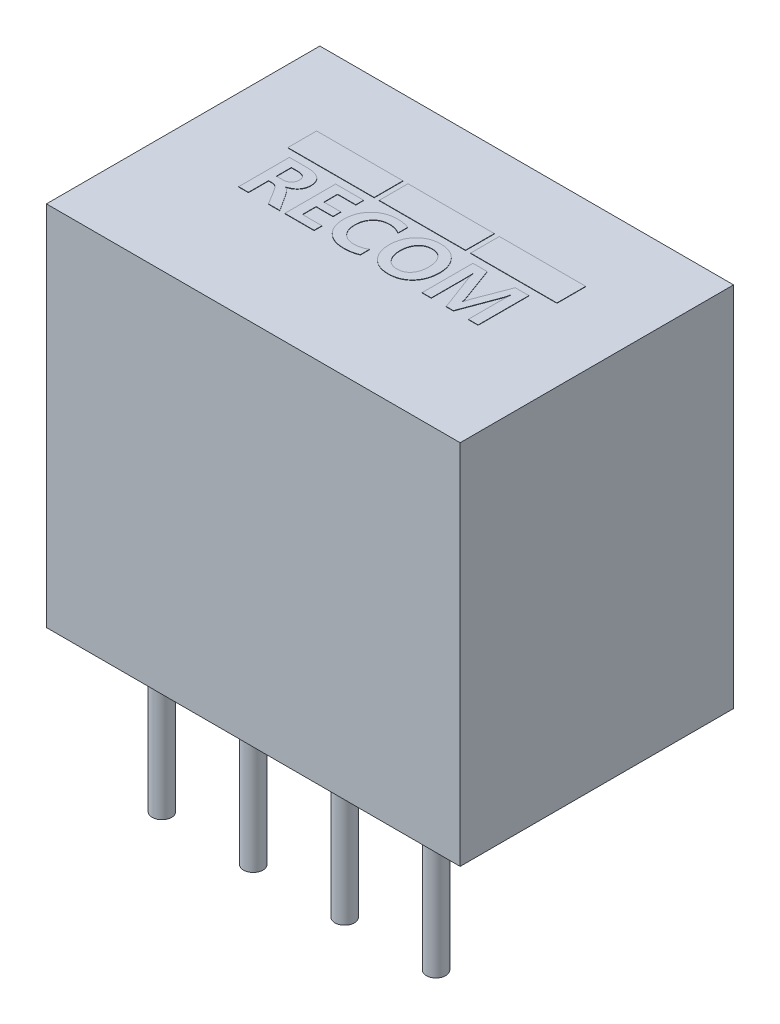
from build123d import *

# Parameters (mm, degrees)
SKETCH1_W           = 11.5
SKETCH1_H           = 7.6
BOSS_EXTRUDE1_DEPTH = 10.2
SKETCH1_3_R         = 0.27
BOSS_EXTRUDE2_DEPTH = 4.1
SKETCH2_W           = 2.4
SKETCH2_H           = 0.8
BOSS_EXTRUDE3_DEPTH = 0.01


with BuildPart() as part:
    # Sketch1 → Boss-Extrude1 (new body)
    with BuildSketch(Plane(origin=(0, 0, 0), x_dir=(1, 0, 0), z_dir=(0, 1, 0))):
        Rectangle(SKETCH1_W, SKETCH1_H)
    extrude(amount=BOSS_EXTRUDE1_DEPTH)

    # Sketch1_3 → Boss-Extrude2 (add)
    with BuildSketch(Plane(origin=(0, 0, 0), x_dir=(1, 0, 0), z_dir=(0, 1, 0))):
        with Locations((-1.27, -2.53)):
            Circle(SKETCH1_3_R)
        with Locations((-3.81, -2.53)):
            Circle(SKETCH1_3_R)
        with Locations((1.27, -2.53)):
            Circle(SKETCH1_3_R)
        with Locations((3.81, -2.53)):
            Circle(SKETCH1_3_R)
    extrude(amount=-BOSS_EXTRUDE2_DEPTH)

    # Sketch2 → Boss-Extrude3 (add)
    # profile 1 of 8: a face of its own
    with BuildSketch(Plane(origin=(0, 10.2, 0), x_dir=(1, 0, 0), z_dir=(0, 1, 0))):
        with Locations((-2.54, 1.3)):
            Rectangle(SKETCH2_W, SKETCH2_H)
    # profile 2 of 8: a face of its own
    with BuildSketch(Plane(origin=(0, 10.2, 0), x_dir=(1, 0, 0), z_dir=(0, 1, 0))):
        with Locations((0, 1.3)):
            Rectangle(SKETCH2_W, SKETCH2_H)
    # profile 3 of 8: a face of its own
    with BuildSketch(Plane(origin=(0, 10.2, 0), x_dir=(1, 0, 0), z_dir=(0, 1, 0))):
        with Locations((2.54, 1.3)):
            Rectangle(SKETCH2_W, SKETCH2_H)
    # profile 4 of 8: a face of its own
    with BuildSketch(Plane(origin=(0, 10.2, 0), x_dir=(1, 0, 0), z_dir=(0, 1, 0))):
        with BuildLine():
            Line((-2.338196915, -0.724408757), (-2.65301943, -0.724408757))
            Line((-2.65301943, -0.724408757), (-2.883342903, -0.349108668))
            add(Edge.make_bspline(
                [(-2.883342903, -0.349108668), (-2.889065834, -0.340050627), (-2.900091741, -0.322599234), (-2.916365352, -0.297671625), (-2.932259878, -0.275279056), (-2.947432976, -0.255296175), (-2.961810385, -0.237635019), (-2.975635139, -0.222577053), (-2.988971428, -0.210025145), (-3.005690975, -0.196649572), (-3.026658096, -0.183273787), (-3.053158879, -0.172174303), (-3.080505396, -0.164993724), (-3.099209874, -0.164144745), (-3.108579478, -0.163719467)],
                knots=[0, 0, 0, 0, 1.260290004, 2.42809852, 3.501063779, 4.489453867, 5.378993215, 6.178776943, 6.892148797, 7.530688844, 8.695813405, 9.803017637, 10.899469084, 12, 12, 12, 12], degree=3))
            Line((-3.108579478, -0.163719467), (-3.210882665, -0.163719467))
            Line((-3.210882665, -0.163719467), (-3.210882665, -0.724408757))
            Line((-3.210882665, -0.724408757), (-3.482183935, -0.724408757))
            Line((-3.482183935, -0.724408757), (-3.482183935, 0.686357844))
            Line((-3.482183935, 0.686357844), (-2.998645943, 0.686357844))
            add(Edge.make_bspline(
                [(-2.998645943, 0.686357844), (-2.978759066, 0.68613297), (-2.940154994, 0.685696448), (-2.884210544, 0.681017461), (-2.832042266, 0.67394387), (-2.783805556, 0.663390469), (-2.739253312, 0.650351489), (-2.698611576, 0.633840907), (-2.661689509, 0.614700878), (-2.628533661, 0.592610205), (-2.599432456, 0.567194833), (-2.57413811, 0.538831914), (-2.552755212, 0.507484911), (-2.535429386, 0.473147775), (-2.521784922, 0.435895451), (-2.51231233, 0.395572491), (-2.50662651, 0.352386367), (-2.505882034, 0.32266239), (-2.505499364, 0.307383883)],
                knots=[0, 0, 0, 0, 1.344225702, 2.609388402, 3.792916859, 4.900986039, 5.94475571, 6.927577767, 7.861970238, 8.752257416, 9.614421308, 10.467028435, 11.314960308, 12.172311822, 13.060888771, 13.990842711, 14.967267346, 16, 16, 16, 16], degree=3))
            add(Edge.make_bspline(
                [(-2.505499364, 0.307383883), (-2.505811899, 0.295977182), (-2.506425671, 0.273576056), (-2.510059685, 0.240455497), (-2.516630851, 0.20852752), (-2.525587337, 0.177659765), (-2.537395774, 0.14804604), (-2.551327957, 0.119384837), (-2.568675725, 0.092288835), (-2.587607134, 0.065874033), (-2.609560455, 0.041454545), (-2.633275923, 0.018262282), (-2.659669621, -0.002502448), (-2.688116325, -0.02157601), (-2.718701939, -0.038719896), (-2.751359485, -0.05444119), (-2.786354582, -0.067957827), (-2.810754066, -0.075239201), (-2.823147934, -0.07893782)],
                knots=[0, 0, 0, 0, 1.012628693, 1.98865752, 2.95290287, 3.90279304, 4.837546914, 5.779899327, 6.726508346, 7.689846888, 8.661316233, 9.637058477, 10.630834735, 11.637334308, 12.674488052, 13.740399365, 14.85222202, 16, 16, 16, 16], degree=3))
            Line((-2.823147934, -0.07893782), (-2.823147934, -0.082894297))
            add(Edge.make_bspline(
                [(-2.823147934, -0.082894297), (-2.814922312, -0.086129796), (-2.797504469, -0.092981001), (-2.772590452, -0.10914122), (-2.746598042, -0.129277061), (-2.720574331, -0.154728798), (-2.693508973, -0.184513059), (-2.666417911, -0.219505154), (-2.637882133, -0.258772484), (-2.619793685, -0.287297436), (-2.610346001, -0.302196156)],
                knots=[0, 0, 0, 0, 0.68144638, 1.442970127, 2.283088423, 3.220039647, 4.250693704, 5.390878668, 6.637243303, 8, 8, 8, 8], degree=3))
            Line((-2.610346001, -0.302196156), (-2.338196915, -0.724408757))
        make_face()
        with BuildLine():
            Line((-3.210882665, 0.469316829), (-3.210882665, 0.053321549))
            Line((-3.210882665, 0.053321549), (-3.044428032, 0.053321549))
            add(Edge.make_bspline(
                [(-3.044428032, 0.053321549), (-3.035184275, 0.053419179), (-3.017111369, 0.05361006), (-2.99079002, 0.057003248), (-2.965738314, 0.061535933), (-2.942334152, 0.068718406), (-2.920289009, 0.077559856), (-2.89952861, 0.088125392), (-2.880608, 0.101464691), (-2.86282623, 0.115902806), (-2.847006029, 0.132099694), (-2.833062523, 0.149401037), (-2.821173153, 0.167749575), (-2.811466768, 0.187074111), (-2.8041627, 0.207316628), (-2.79866061, 0.228385737), (-2.795585693, 0.250583939), (-2.79512334, 0.265737704), (-2.794887385, 0.273471225)],
                knots=[0, 0, 0, 0, 1.187793523, 2.322311229, 3.408112548, 4.458252248, 5.463842587, 6.460858338, 7.445431271, 8.435059429, 9.403096374, 10.350986816, 11.288524295, 12.20955774, 13.125557959, 14.05112169, 15.005416088, 16, 16, 16, 16], degree=3))
            add(Edge.make_bspline(
                [(-2.794887385, 0.273471225), (-2.79496863, 0.281400893), (-2.795126014, 0.296761949), (-2.798677501, 0.318989863), (-2.802715645, 0.339894264), (-2.809734812, 0.359098312), (-2.818544175, 0.376676888), (-2.829026622, 0.393003302), (-2.841524077, 0.407659029), (-2.855779488, 0.421007835), (-2.872460977, 0.432037572), (-2.890436375, 0.442548749), (-2.910880369, 0.450445848), (-2.932873623, 0.457690274), (-2.9569343, 0.462935406), (-2.98282602, 0.466520233), (-3.010569008, 0.468812421), (-3.029727902, 0.469145031), (-3.039623739, 0.469316829)],
                knots=[0, 0, 0, 0, 1.060683122, 2.054715356, 3.010109701, 3.908198541, 4.782933072, 5.640477322, 6.500061802, 7.357420336, 8.246509795, 9.17313587, 10.140950282, 11.174564491, 12.27366142, 13.433661261, 14.67445015, 16, 16, 16, 16], degree=3))
            Line((-3.039623739, 0.469316829), (-3.210882665, 0.469316829))
        make_face(mode=Mode.SUBTRACT)
    # profile 5 of 8: a face of its own
    with BuildSketch(Plane(origin=(0, 10.2, 0), x_dir=(1, 0, 0), z_dir=(0, 1, 0))):
        Polygon((-1.384120784, -0.724408757), (-2.198024592, -0.724408757), (-2.198024592, 0.686357844), (-1.420294286, 0.686357844), (-1.420294286, 0.469316829), (-1.926723323, 0.469316829), (-1.926723323, 0.089495051), (-1.456467789, 0.089495051), (-1.456467789, -0.127545964), (-1.926723323, -0.127545964), (-1.926723323, -0.507367742), (-1.384120784, -0.507367742), align=None)
    # profile 6 of 8: a face of its own
    with BuildSketch(Plane(origin=(0, 10.2, 0), x_dir=(1, 0, 0), z_dir=(0, 1, 0))):
        with BuildLine():
            add(Edge.make_bspline(
                [(-0.154221695, -0.665626815), (-0.167409603, -0.67187969), (-0.194284474, -0.684622059), (-0.237247822, -0.699864047), (-0.28277611, -0.71327562), (-0.331348516, -0.723862351), (-0.382650913, -0.732368187), (-0.436911282, -0.738133908), (-0.493952086, -0.741967244), (-0.533000606, -0.742316716), (-0.55297804, -0.742495509)],
                knots=[0, 0, 0, 0, 0.854610224, 1.741560423, 2.667229016, 3.634022525, 4.652059021, 5.712565366, 6.829736085, 8, 8, 8, 8], degree=3))
            add(Edge.make_bspline(
                [(-0.55297804, -0.742495509), (-0.578444379, -0.742039563), (-0.628227816, -0.741148249), (-0.70089694, -0.731643104), (-0.769826417, -0.71739551), (-0.834591519, -0.696208217), (-0.89548778, -0.669653563), (-0.952459884, -0.637003705), (-1.005140164, -0.597978701), (-1.053812492, -0.553641326), (-1.097415409, -0.504325985), (-1.135733651, -0.450846253), (-1.167658204, -0.393073821), (-1.194060871, -0.331559731), (-1.214378792, -0.266077451), (-1.229061109, -0.196757057), (-1.237943081, -0.123444467), (-1.238925247, -0.073216601), (-1.239426773, -0.047568611)],
                knots=[0, 0, 0, 0, 1.108083605, 2.166161779, 3.185316522, 4.168407951, 5.127001825, 6.073171303, 7.020584339, 7.975671295, 8.934423073, 9.881258946, 10.834097879, 11.802346283, 12.790761351, 13.813926859, 14.883719571, 16, 16, 16, 16], degree=3))
            add(Edge.make_bspline(
                [(-1.239426773, -0.047568611), (-1.2387439, -0.02060115), (-1.237404736, 0.032284041), (-1.227827469, 0.109736336), (-1.211196819, 0.183342659), (-1.188954365, 0.253450352), (-1.159017795, 0.319394577), (-1.123557197, 0.382017535), (-1.080683459, 0.440339723), (-1.032293897, 0.494819523), (-0.978660929, 0.543926423), (-0.920888807, 0.587062483), (-0.859247915, 0.623334197), (-0.794022474, 0.653153909), (-0.725030168, 0.676154145), (-0.652407343, 0.692395546), (-0.576060449, 0.702539506), (-0.523901784, 0.703801217), (-0.497304759, 0.704444596)],
                knots=[0, 0, 0, 0, 1.091637854, 2.140782853, 3.152958058, 4.143081971, 5.112656685, 6.079497617, 7.051289739, 8.037174344, 9.025070473, 9.989908742, 10.950691321, 11.914888765, 12.888094087, 13.889108241, 14.923602787, 16, 16, 16, 16], degree=3))
            add(Edge.make_bspline(
                [(-0.497304759, 0.704444596), (-0.480531854, 0.704318736), (-0.447714472, 0.704072482), (-0.399550067, 0.701063843), (-0.353413615, 0.696730846), (-0.30939758, 0.690146577), (-0.267453406, 0.682134717), (-0.227802001, 0.671788255), (-0.190018316, 0.660174569), (-0.166029253, 0.650449427), (-0.154221695, 0.645662654)],
                knots=[0, 0, 0, 0, 1.148712911, 2.247538656, 3.304355417, 4.321831148, 5.294965487, 6.227707217, 7.127667038, 8, 8, 8, 8], degree=3))
            Line((-0.154221695, 0.645662654), (-0.154221695, 0.374361384))
            add(Edge.make_bspline(
                [(-0.154221695, 0.374361384), (-0.166255433, 0.382007389), (-0.190172346, 0.397203735), (-0.228097588, 0.41634426), (-0.267043903, 0.432848986), (-0.307358642, 0.446047967), (-0.348680556, 0.456653556), (-0.391226398, 0.463831158), (-0.434927527, 0.468619231), (-0.464509425, 0.469082207), (-0.479500613, 0.469316829)],
                knots=[0, 0, 0, 0, 0.994634354, 1.976824218, 2.96110275, 3.944612288, 4.934955791, 5.935959545, 6.954008352, 8, 8, 8, 8], degree=3))
            add(Edge.make_bspline(
                [(-0.479500613, 0.469316829), (-0.496854529, 0.468879937), (-0.530839755, 0.468024346), (-0.580427905, 0.461412342), (-0.627381893, 0.450697498), (-0.671790878, 0.435739121), (-0.713486222, 0.416167602), (-0.752464496, 0.392194269), (-0.788941502, 0.364152859), (-0.822042827, 0.331499457), (-0.852272917, 0.295897538), (-0.878375597, 0.25715655), (-0.900525812, 0.21597559), (-0.918721324, 0.172149685), (-0.932780964, 0.12564865), (-0.942975177, 0.076581322), (-0.948955056, 0.024833129), (-0.949671842, -0.0105315), (-0.950038752, -0.028634043)],
                knots=[0, 0, 0, 0, 1.079563226, 2.114174171, 3.106664841, 4.072415657, 5.024280366, 5.966257424, 6.91477733, 7.880599298, 8.854022165, 9.816476437, 10.781586646, 11.759130548, 12.764126425, 13.799915638, 14.873814758, 16, 16, 16, 16], degree=3))
            add(Edge.make_bspline(
                [(-0.950038752, -0.028634043), (-0.949651597, -0.046358573), (-0.948895828, -0.080958745), (-0.94321182, -0.13155511), (-0.933611615, -0.179384435), (-0.920430116, -0.224599624), (-0.903068646, -0.2670163), (-0.881831926, -0.306685151), (-0.856833518, -0.34362367), (-0.828300711, -0.377609185), (-0.796394527, -0.408041648), (-0.761865779, -0.43474018), (-0.724712012, -0.457305465), (-0.68501653, -0.475743273), (-0.642598076, -0.48984927), (-0.59781807, -0.49990889), (-0.550529483, -0.506395062), (-0.518145332, -0.507038095), (-0.501543841, -0.507367742)],
                knots=[0, 0, 0, 0, 1.149457545, 2.243863635, 3.297126396, 4.310154787, 5.29386799, 6.26426586, 7.223423184, 8.181743352, 9.136785734, 10.077789994, 11.007238446, 11.950323152, 12.91058907, 13.900694878, 14.923807051, 16, 16, 16, 16], degree=3))
            add(Edge.make_bspline(
                [(-0.501543841, -0.507367742), (-0.485705834, -0.507129605), (-0.454340385, -0.506658002), (-0.407911723, -0.501882437), (-0.362552746, -0.49469732), (-0.318483985, -0.484154871), (-0.275481662, -0.470853155), (-0.233785928, -0.454415324), (-0.19304301, -0.435288243), (-0.167203724, -0.420062121), (-0.154221695, -0.412412297)],
                knots=[0, 0, 0, 0, 1.041829192, 2.06322929, 3.068017682, 4.061828653, 5.04211246, 6.027439535, 7.008957229, 8, 8, 8, 8], degree=3))
            Line((-0.154221695, -0.412412297), (-0.154221695, -0.665626815))
        make_face()
    # profile 7 of 8: a face of its own
    with BuildSketch(Plane(origin=(0, 10.2, 0), x_dir=(1, 0, 0), z_dir=(0, 1, 0))):
        with BuildLine():
            add(Edge.make_bspline(
                [(0.008559067, -0.036264391), (0.00914763, -0.009390296), (0.010299315, 0.043196155), (0.019563486, 0.12015096), (0.034415899, 0.193269174), (0.055196599, 0.262568956), (0.082597203, 0.327718632), (0.11579735, 0.389074338), (0.15485186, 0.446667054), (0.19981709, 0.49974578), (0.249689489, 0.547711668), (0.303879197, 0.589832423), (0.362180501, 0.6253942), (0.424529808, 0.654274088), (0.490706014, 0.677023165), (0.560902564, 0.692986727), (0.635003095, 0.702828835), (0.685744624, 0.703898056), (0.711681524, 0.704444596)],
                knots=[0, 0, 0, 0, 1.121472444, 2.194464738, 3.230121258, 4.232697178, 5.209061049, 6.174981034, 7.140164433, 8.108322752, 9.073313906, 10.02341791, 10.967522614, 11.917463873, 12.886133085, 13.882878182, 14.917817871, 16, 16, 16, 16], degree=3))
            add(Edge.make_bspline(
                [(0.711681524, 0.704444596), (0.736299187, 0.703875976), (0.784493595, 0.702762781), (0.854907703, 0.693210504), (0.921687768, 0.677781689), (0.984796788, 0.655929277), (1.044324903, 0.627874813), (1.099863602, 0.593184287), (1.151713839, 0.552366964), (1.199495273, 0.505915591), (1.242619694, 0.454568247), (1.280495499, 0.399283195), (1.312047827, 0.340205689), (1.338441147, 0.277878589), (1.358267211, 0.211863687), (1.372676491, 0.142468897), (1.381693519, 0.069573313), (1.382659062, 0.019718091), (1.383152166, -0.005742998)],
                knots=[0, 0, 0, 0, 1.075105638, 2.104752144, 3.098035666, 4.065079007, 5.016842596, 5.966985372, 6.919558332, 7.8945557, 8.873090516, 9.844511401, 10.816751425, 11.794351104, 12.796800458, 13.822689538, 14.88804632, 16, 16, 16, 16], degree=3))
            add(Edge.make_bspline(
                [(1.383152166, -0.005742998), (1.382529124, -0.032518892), (1.381310309, -0.08489878), (1.372533953, -0.161618828), (1.357545172, -0.234307828), (1.33697607, -0.303298167), (1.310058925, -0.36825856), (1.276989441, -0.429280285), (1.238612597, -0.486800449), (1.193841523, -0.539367199), (1.144685508, -0.587214782), (1.090893373, -0.628628028), (1.033445673, -0.663979243), (0.972131919, -0.692886927), (0.906939565, -0.715364257), (0.837847702, -0.730966149), (0.765005643, -0.74088898), (0.715105833, -0.741952643), (0.689638295, -0.742495509)],
                knots=[0, 0, 0, 0, 1.128167298, 2.20695811, 3.248572207, 4.251931061, 5.236048942, 6.205771933, 7.172394642, 8.14416278, 9.109855911, 10.05785514, 10.998705411, 11.94689576, 12.908468407, 13.898325424, 14.927361119, 16, 16, 16, 16], degree=3))
            add(Edge.make_bspline(
                [(0.689638295, -0.742495509), (0.664832529, -0.741926659), (0.616263374, -0.740812863), (0.545286253, -0.73126062), (0.477946889, -0.715831662), (0.414185242, -0.69395873), (0.354072903, -0.665849862), (0.29732747, -0.631817084), (0.244573757, -0.591069055), (0.19593007, -0.544543389), (0.151964745, -0.493344558), (0.113676299, -0.438156456), (0.080783033, -0.379747169), (0.054726902, -0.317493761), (0.033783076, -0.25210658), (0.019413194, -0.183149953), (0.009932928, -0.110853594), (0.009022916, -0.061447516), (0.008559067, -0.036264391)],
                knots=[0, 0, 0, 0, 1.080052709, 2.114719875, 3.11299101, 4.084866105, 5.044889684, 5.998367451, 6.961017878, 7.941936513, 8.92547754, 9.895236995, 10.863258872, 11.839498082, 12.82959871, 13.849219542, 14.903710337, 16, 16, 16, 16], degree=3))
        make_face()
        with BuildLine():
            add(Edge.make_bspline(
                [(0.297947088, -0.021003695), (0.29825022, -0.038351307), (0.298844662, -0.072369982), (0.304171112, -0.12220763), (0.312088457, -0.169696569), (0.323850028, -0.21475574), (0.338677443, -0.257479788), (0.357245875, -0.29776341), (0.378653129, -0.33584096), (0.403472991, -0.371046686), (0.431018918, -0.403063204), (0.461433796, -0.431007257), (0.494357628, -0.454479219), (0.52945894, -0.474014002), (0.567079268, -0.48901699), (0.607087382, -0.499783173), (0.649503696, -0.505984761), (0.678502455, -0.506900217), (0.693312167, -0.507367742)],
                knots=[0, 0, 0, 0, 1.182102207, 2.318102905, 3.41279402, 4.460921944, 5.488491476, 6.49126631, 7.480442375, 8.462024166, 9.42246041, 10.354133228, 11.270006271, 12.17245588, 13.085804486, 14.023476489, 14.990586372, 16, 16, 16, 16], degree=3))
            add(Edge.make_bspline(
                [(0.693312167, -0.507367742), (0.708689178, -0.50703083), (0.738728145, -0.506372674), (0.782385839, -0.499996343), (0.823468219, -0.489770657), (0.862062152, -0.4758797), (0.897739109, -0.457087425), (0.930973674, -0.434812549), (0.961497991, -0.408194232), (0.989084856, -0.377669893), (1.013701781, -0.343586926), (1.035150859, -0.306548599), (1.053339253, -0.266585813), (1.068302279, -0.223842764), (1.079886666, -0.178067475), (1.087938861, -0.129477681), (1.092789292, -0.078000267), (1.093433282, -0.042775172), (1.093764145, -0.024677566)],
                knots=[0, 0, 0, 0, 1.04008275, 2.031799996, 2.978052724, 3.901789991, 4.799963908, 5.699945926, 6.603713185, 7.533414636, 8.478313501, 9.443805081, 10.425141019, 11.445340204, 12.504473104, 13.616449264, 14.775402507, 16, 16, 16, 16], degree=3))
            add(Edge.make_bspline(
                [(1.093764145, -0.024677566), (1.093435633, -0.006014824), (1.092795724, 0.030338405), (1.087921516, 0.083302273), (1.080099211, 0.133173743), (1.069159999, 0.180101574), (1.054748054, 0.223968598), (1.037216525, 0.26485603), (1.016590599, 0.302755688), (0.992471996, 0.337223653), (0.965775117, 0.368394043), (0.936176838, 0.395594677), (0.90365305, 0.41825172), (0.868723326, 0.43710943), (0.830979271, 0.451541927), (0.790709859, 0.461967412), (0.747773987, 0.468313213), (0.718297707, 0.468976943), (0.703203359, 0.469316829)],
                knots=[0, 0, 0, 0, 1.257698234, 2.449875369, 3.581369221, 4.657836076, 5.693848385, 6.689260428, 7.652525348, 8.596578619, 9.519384408, 10.413706029, 11.297941717, 12.184203774, 13.082662672, 14.0143372, 14.983172764, 16, 16, 16, 16], degree=3))
            add(Edge.make_bspline(
                [(0.703203359, 0.469316829), (0.687823538, 0.468890255), (0.657862788, 0.468059265), (0.614193111, 0.461357661), (0.573032871, 0.450702902), (0.534245557, 0.435691572), (0.498040122, 0.416054225), (0.464657075, 0.39177544), (0.433466248, 0.363617843), (0.405449783, 0.331013454), (0.380190402, 0.295285662), (0.357967305, 0.257050716), (0.339693805, 0.216308468), (0.324266733, 0.173466031), (0.312487195, 0.128141635), (0.304072064, 0.080517527), (0.298861452, 0.030546499), (0.298256432, -0.003563409), (0.297947088, -0.021003695)],
                knots=[0, 0, 0, 0, 1.031871387, 2.010143012, 2.957922701, 3.880826205, 4.794696888, 5.71421533, 6.64524859, 7.608841036, 8.593040831, 9.578864117, 10.572060904, 11.586032239, 12.631968733, 13.71101741, 14.829650584, 16, 16, 16, 16], degree=3))
        make_face(mode=Mode.SUBTRACT)
    # profile 8 of 8: a face of its own
    with BuildSketch(Plane(origin=(0, 10.2, 0), x_dir=(1, 0, 0), z_dir=(0, 1, 0))):
        with BuildLine():
            Line((2.902439275, -0.724408757), (2.902439275, 0.155907341))
            add(Edge.make_bspline(
                [(2.902439275, 0.155907341), (2.902422745, 0.164479746), (2.902387687, 0.182661241), (2.902686764, 0.211582634), (2.90335047, 0.243702324), (2.903790926, 0.279032094), (2.904779097, 0.317556061), (2.905509395, 0.359292013), (2.906674945, 0.404226136), (2.907608812, 0.435216119), (2.908091385, 0.451230077)],
                knots=[0, 0, 0, 0, 0.696500254, 1.477230364, 2.349903411, 3.306756983, 4.34793366, 5.480935998, 6.698283018, 8, 8, 8, 8], degree=3))
            Line((2.908091385, 0.451230077), (2.902439275, 0.451230077))
            add(Edge.make_bspline(
                [(2.902439275, 0.451230077), (2.898707068, 0.432361088), (2.891800038, 0.397441086), (2.880433644, 0.349697527), (2.870046039, 0.310454055), (2.862138488, 0.287566807), (2.858635424, 0.277427702)],
                knots=[0, 0, 0, 0, 1.286433987, 2.380746357, 3.282666784, 4, 4, 4, 4], degree=3))
            Line((2.858635424, 0.277427702), (2.486443995, -0.724408757))
            Line((2.486443995, -0.724408757), (2.287489731, -0.724408757))
            Line((2.287489731, -0.724408757), (1.915015696, 0.268666931))
            add(Edge.make_bspline(
                [(1.915015696, 0.268666931), (1.913649237, 0.272419747), (1.910537747, 0.280965082), (1.906564202, 0.295686611), (1.901596393, 0.313517039), (1.896663352, 0.33478), (1.891033892, 0.359276), (1.884713248, 0.387024215), (1.878359629, 0.418068868), (1.873853991, 0.439832672), (1.871494451, 0.451230077)],
                knots=[0, 0, 0, 0, 0.51018959, 1.161725134, 1.94728856, 2.87582812, 3.950511025, 5.159663206, 6.512554521, 8, 8, 8, 8], degree=3))
            Line((1.871494451, 0.451230077), (1.864994525, 0.451230077))
            add(Edge.make_bspline(
                [(1.864994525, 0.451230077), (1.866010525, 0.424478943), (1.868088671, 0.369761714), (1.869847471, 0.286004868), (1.871505988, 0.198869761), (1.871498345, 0.13970554), (1.871494451, 0.109560041)],
                knots=[0, 0, 0, 0, 0.939968096, 1.922626911, 2.941531806, 4, 4, 4, 4], degree=3))
            Line((1.871494451, 0.109560041), (1.871494451, -0.724408757))
            Line((1.871494451, -0.724408757), (1.618279933, -0.724408757))
            Line((1.618279933, -0.724408757), (1.618279933, 0.686357844))
            Line((1.618279933, 0.686357844), (2.016188461, 0.686357844))
            Line((2.016188461, 0.686357844), (2.339206535, -0.190566988))
            add(Edge.make_bspline(
                [(2.339206535, -0.190566988), (2.345615566, -0.208119388), (2.357965055, -0.24194091), (2.372756248, -0.291940133), (2.385059703, -0.338590837), (2.390365956, -0.369037456), (2.392901578, -0.383586537)],
                knots=[0, 0, 0, 0, 1.117134628, 2.152594111, 3.117207157, 4, 4, 4, 4], degree=3))
            Line((2.392901578, -0.383586537), (2.399401504, -0.383586537))
            add(Edge.make_bspline(
                [(2.399401504, -0.383586537), (2.403165406, -0.369145853), (2.411071651, -0.338812545), (2.425444412, -0.292041819), (2.441136852, -0.24131638), (2.453090054, -0.206642702), (2.459313868, -0.18858875)],
                knots=[0, 0, 0, 0, 0.877518454, 1.843267155, 2.877028553, 4, 4, 4, 4], degree=3))
            Line((2.459313868, -0.18858875), (2.793918767, 0.686357844))
            Line((2.793918767, 0.686357844), (3.173740545, 0.686357844))
            Line((3.173740545, 0.686357844), (3.173740545, -0.724408757))
            Line((3.173740545, -0.724408757), (2.902439275, -0.724408757))
        make_face()
    extrude(amount=BOSS_EXTRUDE3_DEPTH)


solid = part.part
